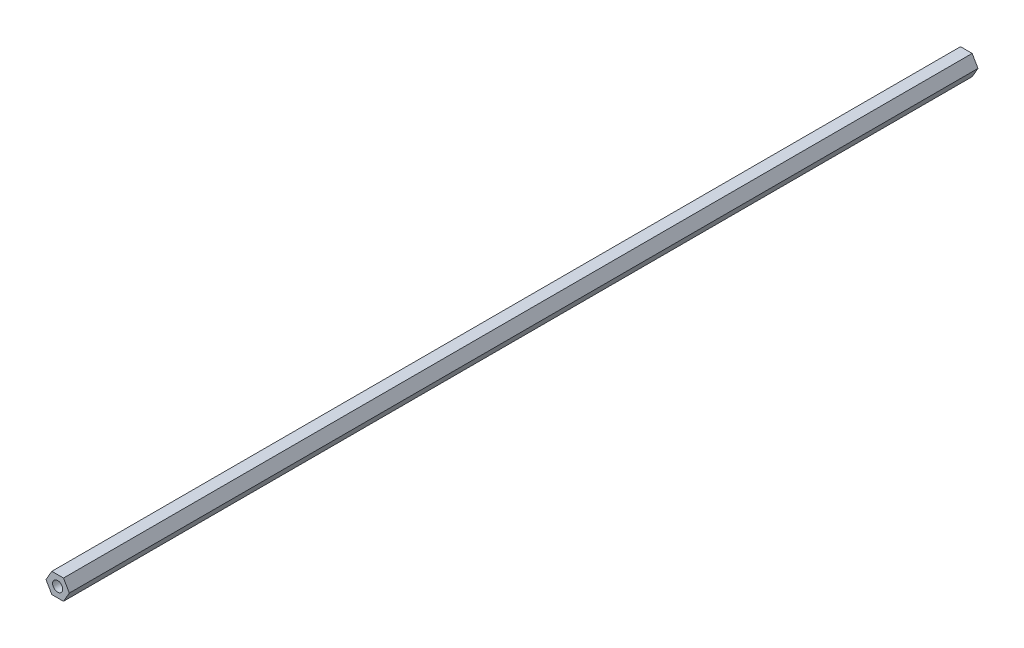
from build123d import *

# Parameters (mm, degrees)
BOSS_EXTRUDE1_DEPTH     = 514.48335
SKETCH2_R               = 3.175
CUT_EXTRUDE1_DEPTH      = 1
CUT_EXTRUDE1_DEPTH_BACK = 515.48335
SKETCH3_R               = 3.175
BOSS_EXTRUDE2_DEPTH     = 571.5


with BuildPart() as part:
    # Sketch1 → Boss-Extrude1 (new body)
    with BuildSketch(Plane.XY):
        Polygon((-7.332348419, 0), (-3.666174209, -6.35), (3.666174209, -6.35), (7.332348419, 0), (3.666174209, 6.35), (-3.666174209, 6.35), align=None)
    extrude(amount=BOSS_EXTRUDE1_DEPTH)

    # Sketch2 → Cut-Extrude1 (cut, two sides)
    with BuildSketch(Plane.XY.offset(514.48335)) as cut_extrude1_sk:
        Circle(SKETCH2_R)
    extrude(amount=CUT_EXTRUDE1_DEPTH, mode=Mode.SUBTRACT)
    extrude(cut_extrude1_sk.sketch, amount=-CUT_EXTRUDE1_DEPTH_BACK, mode=Mode.SUBTRACT)

    # Sketch3 → Boss-Extrude2 (add)
    with BuildSketch(Plane.XY.offset(514.48335)):
        Polygon((-3.666174209, -6.35), (3.666174209, -6.35), (7.332348419, 0), (3.666174209, 6.35), (-3.666174209, 6.35), (-7.332348419, 0), align=None)
        Circle(SKETCH3_R, mode=Mode.SUBTRACT)
    extrude(amount=-BOSS_EXTRUDE2_DEPTH)


solid = part.part
